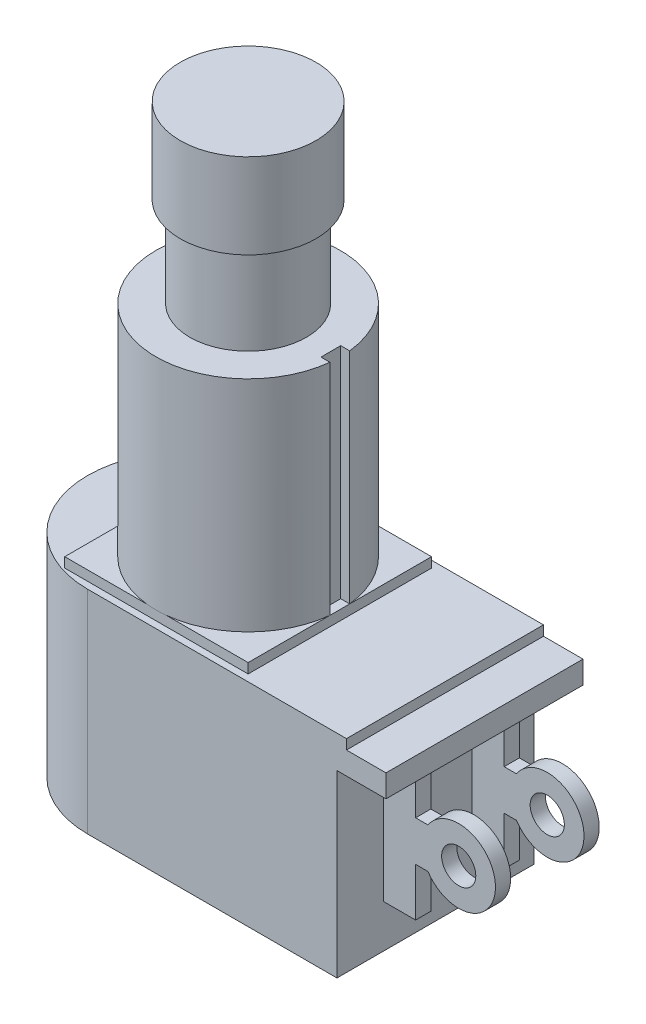
from build123d import *

# Parameters (mm, degrees)
SKETCH2_W           = 11.7856
SKETCH2_H           = 11.7856
BOSS_EXTRUDE1_DEPTH = 0.635
BOSS_EXTRUDE2_DEPTH = 0.635
BOSS_EXTRUDE3_DEPTH = 1.4478
BOSS_EXTRUDE4_DEPTH = 11.5443
SKETCH6_R           = 1.09855
BOSS_EXTRUDE5_DEPTH = 0.9779
SKETCH7_W           = 1.509743552
SKETCH7_H           = 1.27
CUT_EXTRUDE1_DEPTH  = 14.0843


with BuildPart() as part:
    # Sketch1 → Revolve1 (revolve)
    with BuildSketch(Plane.XY):
        Polygon((0, 0), (5.925, 0), (5.925, 14.0843), (3.75, 14.0843), (3.75, 19.8755), (4.36245, 19.8755), (4.36245, 25.3365), (0, 25.3365), align=None)
    revolve(axis=Axis((0, 31.195966839, 0), (0, -1, 0)))

    # Sketch2 → Boss-Extrude1 (add)
    with BuildSketch(Plane.XZ):
        Rectangle(SKETCH2_W, SKETCH2_H)
    extrude(amount=BOSS_EXTRUDE1_DEPTH)

    # Sketch3 → Boss-Extrude2 (add)
    with BuildSketch(Plane.XZ.offset(0.635)):
        with BuildLine():
            Line((-3.98145, 6.33095), (12.6492, 6.33095))
            Line((12.6492, 6.33095), (12.6492, -6.33095))
            Line((12.6492, -6.33095), (-3.98145, -6.33095))
            ThreePointArc((-3.98145, -6.33095), (-10.3124, 0), (-3.98145, 6.33095))
        make_face()
    extrude(amount=BOSS_EXTRUDE2_DEPTH)

    # Sketch4 → Boss-Extrude3 (add)
    with BuildSketch(Plane.XZ.offset(1.27)):
        with BuildLine():
            Line((-3.98145, -6.33095), (15.1892, -6.33095))
            Line((15.1892, -6.33095), (15.1892, 6.33095))
            Line((15.1892, 6.33095), (-3.98145, 6.33095))
            ThreePointArc((-3.98145, 6.33095), (-10.3124, 0), (-3.98145, -6.33095))
        make_face()
    extrude(amount=BOSS_EXTRUDE3_DEPTH)

    # Sketch5 → Boss-Extrude4 (add)
    with BuildSketch(Plane.XZ.offset(2.7178)):
        with BuildLine():
            Line((12.0396, 6.33095), (-3.98145, 6.33095))
            ThreePointArc((-3.98145, 6.33095), (-10.3124, 0), (-3.98145, -6.33095))
            Line((-3.98145, -6.33095), (12.0396, -6.33095))
            Line((12.0396, -6.33095), (12.0396, 6.33095))
        make_face()
    extrude(amount=BOSS_EXTRUDE4_DEPTH)

    # Sketch6 → Boss-Extrude5 (add)
    with BuildSketch(Plane.XY.offset(3.33375)):
        with BuildLine():
            Line((14.097, -8.4074), (14.097, -11.5062))
            Line((14.097, -11.5062), (12.0396, -11.5062))
            Line((12.0396, -11.5062), (12.0396, -2.7178))
            Line((12.0396, -2.7178), (14.097, -2.7178))
            Line((14.097, -2.7178), (14.097, -5.8166))
            Line((14.097, -5.8166), (14.890270235, -5.8166))
            ThreePointArc((14.890270235, -5.8166), (19.2278, -7.112), (14.890270235, -8.4074))
            Line((14.890270235, -8.4074), (14.097, -8.4074))
        make_face()
        with Locations((16.8656, -7.112)):
            Circle(SKETCH6_R, mode=Mode.SUBTRACT)
    boss_extrude5 = extrude(amount=-BOSS_EXTRUDE5_DEPTH)

    # Mirror1: Boss-Extrude5 across plane
    add(boss_extrude5.mirror(Plane.XY))

    # Sketch7 → Cut-Extrude1 (cut)
    with BuildSketch(Plane(origin=(0, 14.0843, 0), x_dir=(1, 0, 0), z_dir=(0, 1, 0))):
        with Locations((6.070418397, 0)):
            Rectangle(SKETCH7_W, SKETCH7_H)
    extrude(amount=-CUT_EXTRUDE1_DEPTH, mode=Mode.SUBTRACT)


solid = part.part
